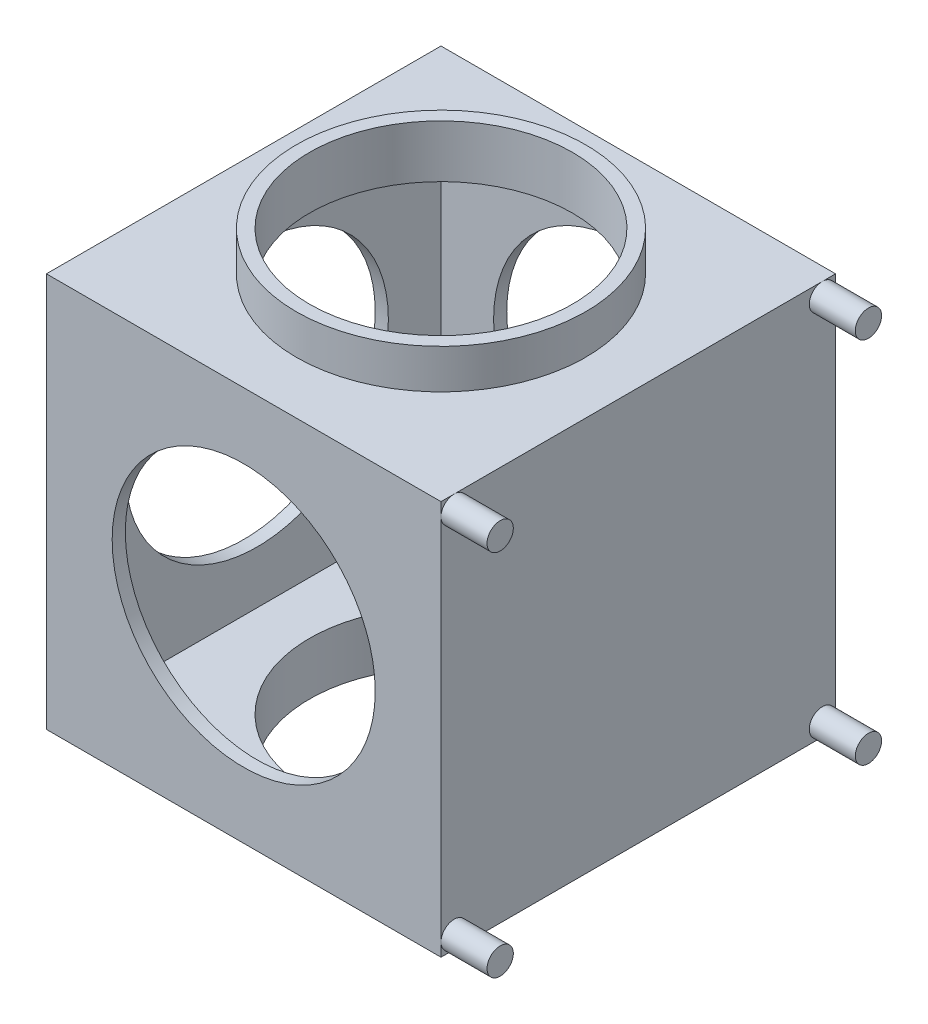
from build123d import *

# Parameters (mm, degrees)
SKETCH1_W           = 300
SKETCH1_H           = 300
BOSS_EXTRUDE1_DEPTH = 300
SKETCH2_W           = 280
SKETCH2_H           = 280
CUT_EXTRUDE1_DEPTH  = 290
SKETCH5_W           = 300
SKETCH5_H           = 300
BOSS_EXTRUDE3_DEPTH = 10
SKETCH6_R           = 100
CUT_EXTRUDE3_DEPTH  = 301
CUT_EXTRUDE4_DEPTH  = 301
CUT_EXTRUDE5_DEPTH  = 10
SKETCH9_R           = 10
BOSS_EXTRUDE4_DEPTH = 35
SKETCH10_R          = 110
SKETCH10_R_2        = 100
BOSS_EXTRUDE5_DEPTH = 30
SKETCH11_R          = 110
SKETCH11_R_2        = 100
BOSS_EXTRUDE6_DEPTH = 30


with BuildPart() as part:
    # Sketch1 → Boss-Extrude1 (new body)
    with BuildSketch(Plane(origin=(0, 0, 0), x_dir=(1, 0, 0), z_dir=(0, 1, 0))):
        Rectangle(SKETCH1_W, SKETCH1_H)
    extrude(amount=BOSS_EXTRUDE1_DEPTH)

    # Sketch2 → Cut-Extrude1 (cut)
    with BuildSketch(Plane(origin=(0, 300, 0), x_dir=(1, 0, 0), z_dir=(0, 1, 0))):
        Rectangle(SKETCH2_W, SKETCH2_H)
    extrude(amount=-CUT_EXTRUDE1_DEPTH, mode=Mode.SUBTRACT)

    # Sketch5 → Boss-Extrude3 (add)
    with BuildSketch(Plane(origin=(0, 300, 0), x_dir=(1, 0, 0), z_dir=(0, 1, 0))):
        Rectangle(SKETCH5_W, SKETCH5_H)
    extrude(amount=-BOSS_EXTRUDE3_DEPTH)

    # Sketch6 → Cut-Extrude3 (cut, through all)
    with BuildSketch(Plane(origin=(0, 300, 0), x_dir=(1, 0, 0), z_dir=(0, 1, 0))):
        Circle(SKETCH6_R)
    extrude(amount=-CUT_EXTRUDE3_DEPTH, mode=Mode.SUBTRACT)

    # Sketch7 → Cut-Extrude4 (cut, through all)
    with BuildSketch(Plane(origin=(0, 0, -150), x_dir=(-1, 0, 0), z_dir=(0, 0, -1))):
        with BuildLine():
            ThreePointArc((100, 150), (70.710678119, 220.710678119), (0, 250))
            Line((0, 250), (0, 50))
            ThreePointArc((0, 50), (70.710678119, 79.289321881), (100, 150))
        make_face()
        with BuildLine():
            Line((0, 50), (0, 250))
            ThreePointArc((0, 250), (-100, 150), (0, 50))
        make_face()
    extrude(amount=-CUT_EXTRUDE4_DEPTH, mode=Mode.SUBTRACT)

    # Sketch8 → Cut-Extrude5 (cut)
    with BuildSketch(Plane.ZY.offset(150)):
        with BuildLine():
            ThreePointArc((0, 250), (-100, 150), (0, 50))
            Line((0, 50), (0, 250))
        make_face()
        with BuildLine():
            Line((0, 250), (0, 50))
            ThreePointArc((0, 50), (70.710678119, 79.289321881), (100, 150))
            ThreePointArc((100, 150), (70.710678119, 220.710678119), (0, 250))
        make_face()
    extrude(amount=-CUT_EXTRUDE5_DEPTH, mode=Mode.SUBTRACT)

    # Sketch9 → Boss-Extrude4 (add)
    with BuildSketch(Plane(origin=(150, 0, 0), x_dir=(0, 0, -1), z_dir=(1, 0, 0))):
        with Locations((140, 290)):
            Circle(SKETCH9_R)
        with Locations((140, 10)):
            Circle(SKETCH9_R)
        with Locations((-140, 290)):
            Circle(SKETCH9_R)
        with BuildLine():
            ThreePointArc((-130, 10), (-132.928932188, 17.071067812), (-140, 20))
            Line((-140, 20), (-140, 0))
            ThreePointArc((-140, 0), (-132.928932188, 2.928932188), (-130, 10))
        make_face()
        with BuildLine():
            Line((-140, 0), (-140, 20))
            ThreePointArc((-140, 20), (-147.071067812, 17.071067812), (-150, 10))
            ThreePointArc((-150, 10), (-147.071067812, 2.928932188), (-140, 0))
        make_face()
    extrude(amount=BOSS_EXTRUDE4_DEPTH)

    # Sketch10 → Boss-Extrude5 (add)
    with BuildSketch(Plane(origin=(0, 300, 0), x_dir=(1, 0, 0), z_dir=(0, 1, 0))):
        Circle(SKETCH10_R)
        Circle(SKETCH10_R_2, mode=Mode.SUBTRACT)
    extrude(amount=BOSS_EXTRUDE5_DEPTH)

    # Sketch11 → Boss-Extrude6 (add)
    with BuildSketch(Plane.XZ):
        Circle(SKETCH11_R)
        Circle(SKETCH11_R_2, mode=Mode.SUBTRACT)
    extrude(amount=BOSS_EXTRUDE6_DEPTH)


solid = part.part
